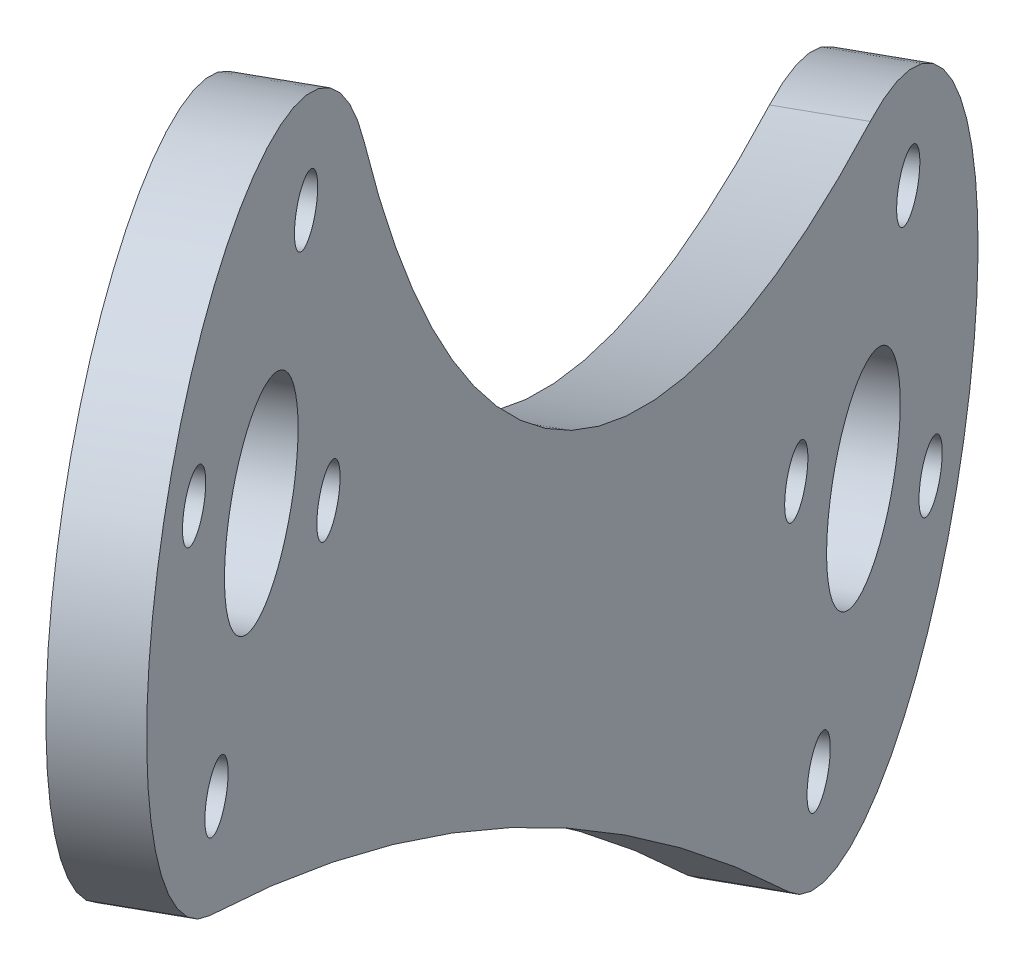
from build123d import *

# Parameters (mm, degrees)
SKETCH1_R           = 1.2192
SKETCH1_R_2         = 3.8735
BOSS_EXTRUDE1_DEPTH = 3


with BuildPart() as part:
    # Sketch1 → Boss-Extrude1 (new body)
    with BuildSketch(Plane(origin=(22.066943297, 0, -12.337708943), x_dir=(0, -1, 0), z_dir=(-0.872839337, 0, 0.488007675))):
        with BuildLine():
            ThreePointArc((-72.947857894, 167.897835008), (-47.979019161, 146.065099757), (-37.424383054, 114.621326243))
            ThreePointArc((-37.424383054, 114.621326243), (-20.859592098, 104.154397101), (-16.22026224, 123.191873917))
            ThreePointArc((-16.22026224, 123.191873917), (-38.39182686, 152.45760543), (-56.883606586, 184.176927637))
            ThreePointArc((-56.883606586, 184.176927637), (-76.241477877, 187.213656824), (-72.947857894, 167.897835008))
        make_face()
        with Locations((-32.452983518, 110.624678087)):
            Circle(SKETCH1_R, mode=Mode.SUBTRACT)
        with Locations((-20.665274094, 108.268060476)):
            Circle(SKETCH1_R, mode=Mode.SUBTRACT)
        with Locations((-18.308656482, 120.055769899)):
            Circle(SKETCH1_R, mode=Mode.SUBTRACT)
        with Locations((-30.096365906, 122.412387511)):
            Circle(SKETCH1_R, mode=Mode.SUBTRACT)
        with Locations((-62.938209154, 171.667105905)):
            Circle(SKETCH1_R, mode=Mode.SUBTRACT)
        with Locations((-60.581591542, 183.454815329)):
            Circle(SKETCH1_R, mode=Mode.SUBTRACT)
        with Locations((-72.369300966, 185.811432941)):
            Circle(SKETCH1_R, mode=Mode.SUBTRACT)
        with Locations((-74.725918578, 174.023723517)):
            Circle(SKETCH1_R, mode=Mode.SUBTRACT)
        with Locations((-67.65375506, 178.739269423)):
            Circle(SKETCH1_R_2, mode=Mode.SUBTRACT)
        with Locations((-25.38082, 115.340223993)):
            Circle(SKETCH1_R_2, mode=Mode.SUBTRACT)
    extrude(amount=-BOSS_EXTRUDE1_DEPTH)


solid = part.part
